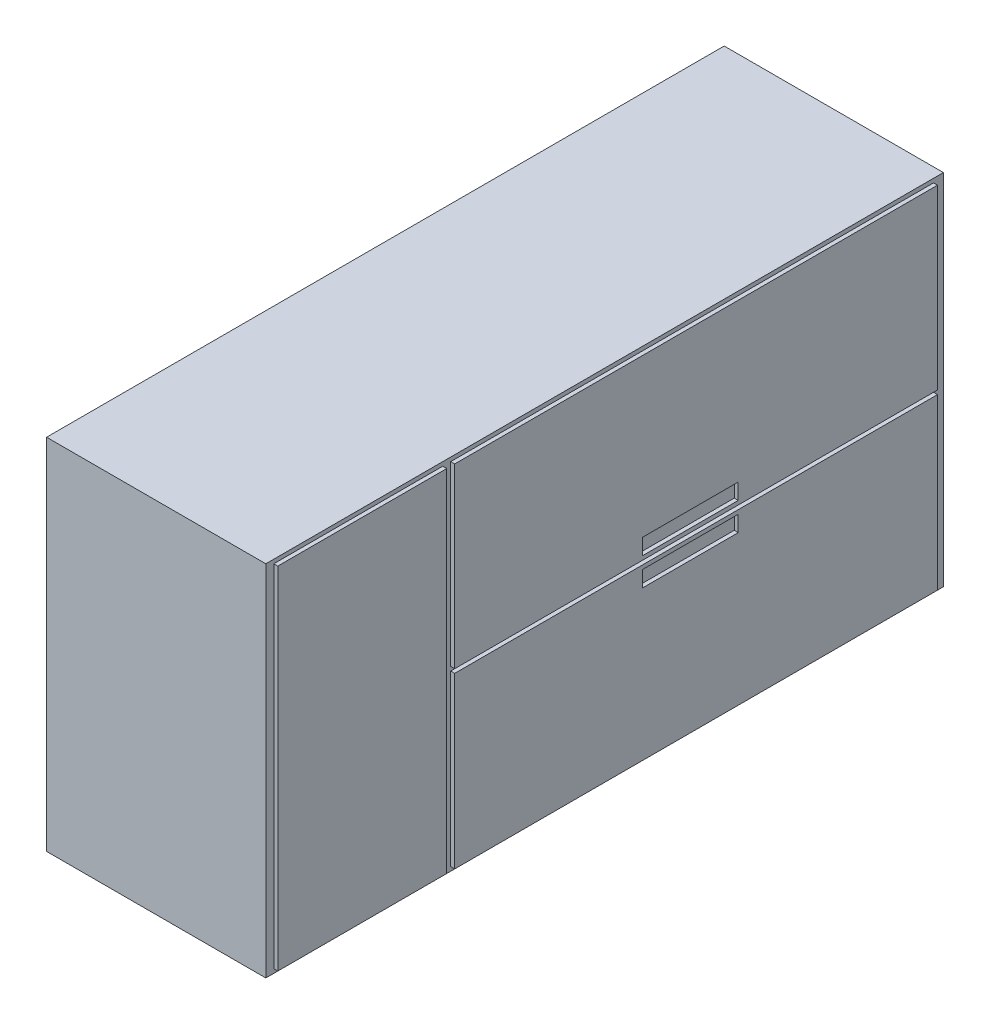
from build123d import *

# Parameters (mm, degrees)
SKETCH1_W           = 550
SKETCH1_H           = 900
BOSS_EXTRUDE1_DEPTH = 1700
SKETCH2_W           = 423.908990982
SKETCH2_H           = 880
SKETCH2_W_2         = 1211.324213984
SKETCH2_H_2         = 445
SKETCH2_W_3         = 240
SKETCH2_H_3         = 40
SKETCH2_H_4         = 425
BOSS_EXTRUDE2_DEPTH = 10


with BuildPart() as part:
    # Sketch1 → Boss-Extrude1 (new body)
    with BuildSketch(Plane.XY):
        with Locations((-275, -450)):
            Rectangle(SKETCH1_W, SKETCH1_H)
    extrude(amount=BOSS_EXTRUDE1_DEPTH)

    # Sketch2 → Boss-Extrude2 (add)
    with BuildSketch(Plane(origin=(0, 0, 0), x_dir=(0, 0, -1), z_dir=(1, 0, 0))):
        with Locations((-1468.045504509, -450)):
            Rectangle(SKETCH2_W, SKETCH2_H)
        with Locations((-630.428902026, -232.5)):
            Rectangle(SKETCH2_W_2, SKETCH2_H_2)
        with Locations((-644.725938912, -425)):
            Rectangle(SKETCH2_W_3, SKETCH2_H_3, mode=Mode.SUBTRACT)
        with Locations((-630.428902026, -677.5)):
            Rectangle(SKETCH2_W_2, SKETCH2_H_4)
        with Locations((-644.725938912, -495)):
            Rectangle(SKETCH2_W_3, SKETCH2_H_3, mode=Mode.SUBTRACT)
    extrude(amount=BOSS_EXTRUDE2_DEPTH)


solid = part.part
